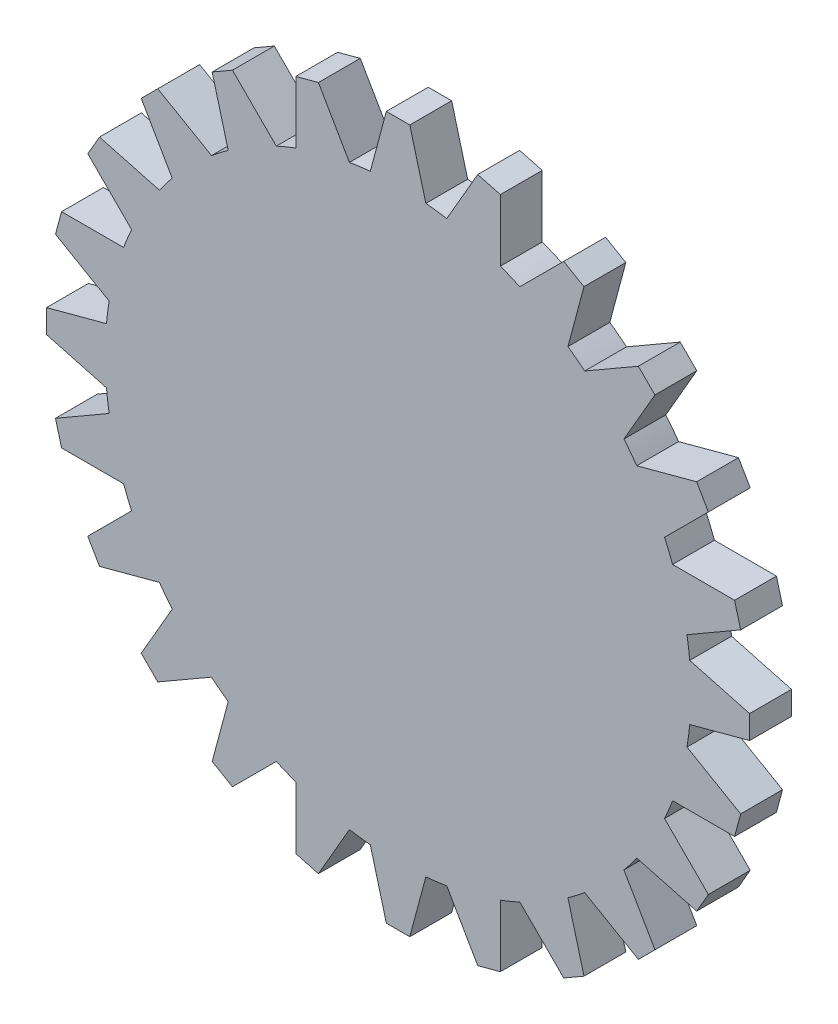
from build123d import *

# Parameters (mm, degrees)
SKETCH1_R           = 7
BOSS_EXTRUDE1_DEPTH = 1
BOSS_EXTRUDE2_DEPTH = 1
CIRPATTERN1_COUNT   = 24


with BuildPart() as part:
    # Sketch1 → Boss-Extrude1 (new body)
    with BuildSketch(Plane.XY):
        Circle(SKETCH1_R)
    extrude(amount=BOSS_EXTRUDE1_DEPTH)

    # Sketch2 → Boss-Extrude2 (add)
    with BuildSketch(Plane.XY):
        Polygon((0, 6.72), (-0.730154643, 6.72), (-0.28, 8.4), (0.28, 8.4), (0.730154643, 6.72), align=None)
    boss_extrude2 = extrude(amount=BOSS_EXTRUDE2_DEPTH)

    # CirPattern1: Boss-Extrude2 ×24 about axis
    cirpattern1_axis = Axis((0, 0, 0), (0, 0, 1))
    for i in range(1, CIRPATTERN1_COUNT):
        add(boss_extrude2.rotate(cirpattern1_axis, i * 360 / CIRPATTERN1_COUNT))


solid = part.part
